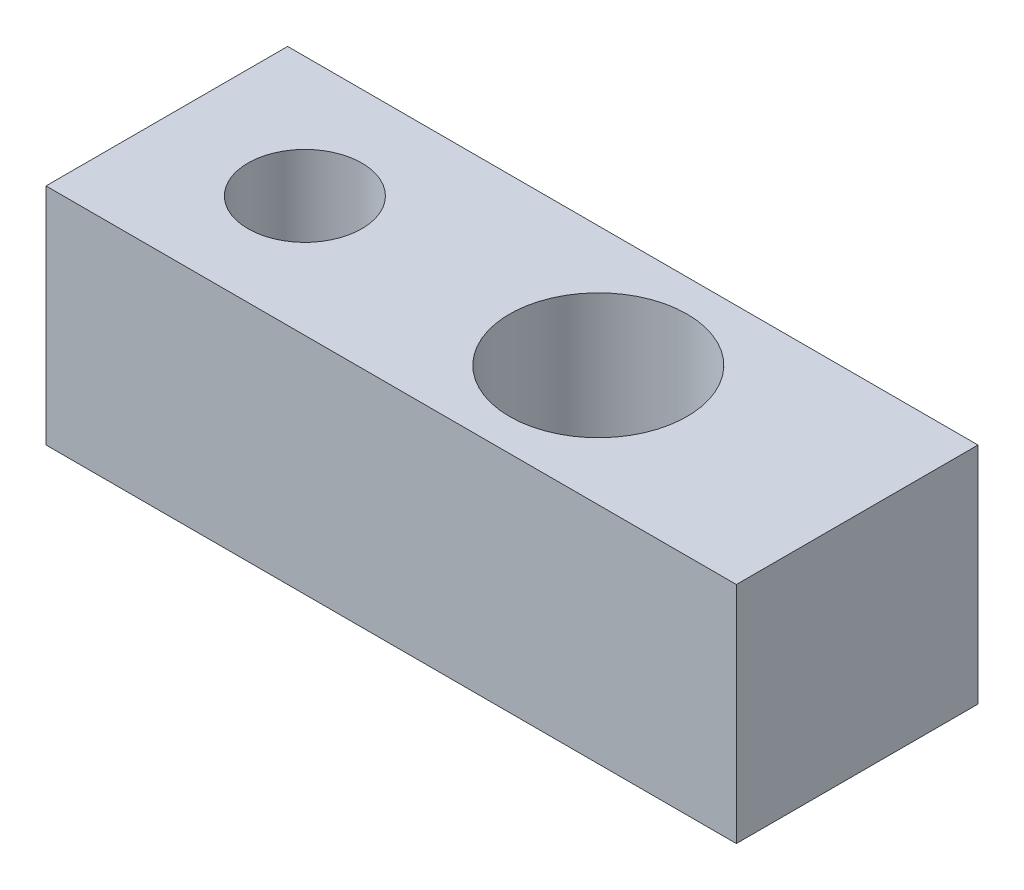
from build123d import *

# Parameters (mm, degrees)
SKETCH1_W           = 20
SKETCH1_H           = 7
SKETCH1_R           = 1.65
SKETCH1_R_2         = 2.571857311
BOSS_EXTRUDE1_DEPTH = 6.5


with BuildPart() as part:
    # Sketch1 → Boss-Extrude1 (new body)
    with BuildSketch(Plane(origin=(0, 0, 0), x_dir=(1, 0, 0), z_dir=(0, 1, 0))):
        with Locations((6, 0)):
            Rectangle(SKETCH1_W, SKETCH1_H)
        Circle(SKETCH1_R, mode=Mode.SUBTRACT)
        with Locations((8.5, 0)):
            Circle(SKETCH1_R_2, mode=Mode.SUBTRACT)
    extrude(amount=BOSS_EXTRUDE1_DEPTH)


solid = part.part
